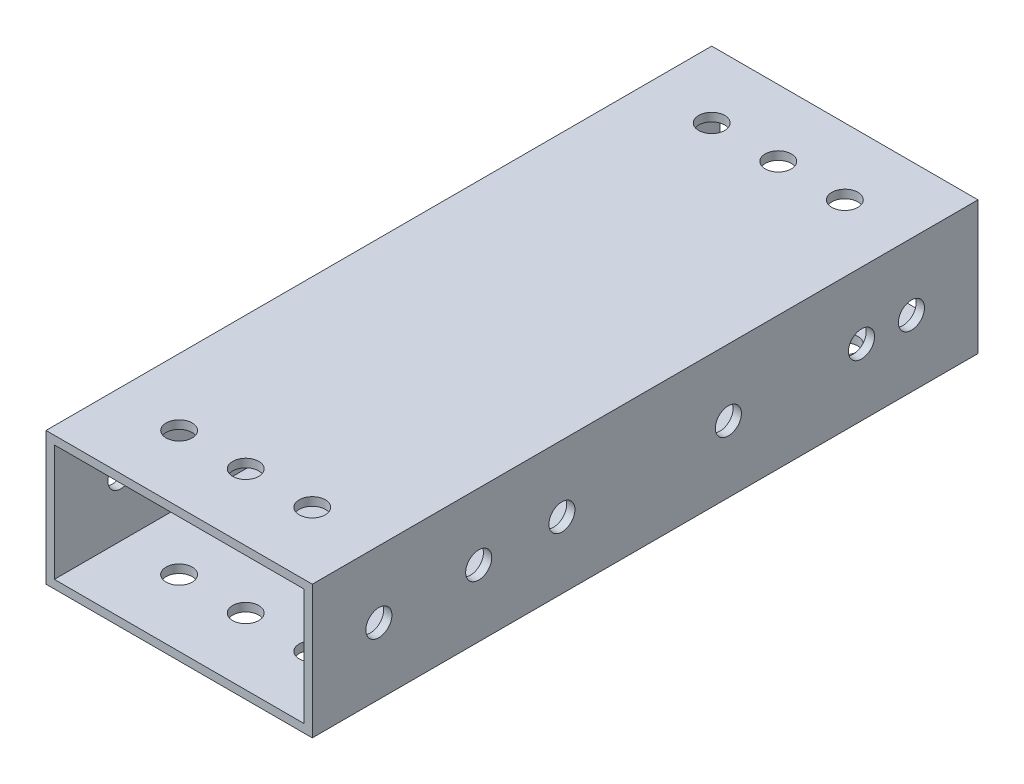
from build123d import *

# Parameters (mm, degrees)
SKETCH1_W           = 50.8
SKETCH1_H           = 25.4
SKETCH1_W_2         = 47.625
SKETCH1_H_2         = 22.225
BOSS_EXTRUDE1_DEPTH = 63.5
SKETCH2_R           = 2.4892
CUT_EXTRUDE1_DEPTH  = 26.4
SKETCH3_R           = 2.4892
CUT_EXTRUDE2_DEPTH  = 51.8


with BuildPart() as part:
    # Sketch1 → Boss-Extrude1 (new body, symmetric)
    with BuildSketch(Plane.XY):
        Rectangle(SKETCH1_W, SKETCH1_H)
        Rectangle(SKETCH1_W_2, SKETCH1_H_2, mode=Mode.SUBTRACT)
    extrude(amount=BOSS_EXTRUDE1_DEPTH, both=True)

    # Sketch2 → Cut-Extrude1 (cut, through all)
    with BuildSketch(Plane(origin=(0, 12.7, 0), x_dir=(1, 0, 0), z_dir=(0, 1, 0))):
        with Locations((-12.7, 50.8)):
            Circle(SKETCH2_R)
        with Locations((0, 50.8)):
            Circle(SKETCH2_R)
        with Locations((12.7, 50.8)):
            Circle(SKETCH2_R)
        with Locations((12.7, -50.8)):
            Circle(SKETCH2_R)
        with Locations((0, -50.8)):
            Circle(SKETCH2_R)
        with Locations((-12.7, -50.8)):
            Circle(SKETCH2_R)
    extrude(amount=-CUT_EXTRUDE1_DEPTH, mode=Mode.SUBTRACT)

    # Sketch3 → Cut-Extrude2 (cut, through all)
    with BuildSketch(Plane(origin=(25.4, 0, 0), x_dir=(0, 0, -1), z_dir=(1, 0, 0))):
        with Locations((50.8, 0)):
            Circle(SKETCH3_R)
        with Locations((41.275, 0)):
            Circle(SKETCH3_R)
        with Locations((15.875, 0)):
            Circle(SKETCH3_R)
        with Locations((-50.8, 0)):
            Circle(SKETCH3_R)
        with Locations((-31.75, 0)):
            Circle(SKETCH3_R)
        with Locations((-15.875, 0)):
            Circle(SKETCH3_R)
    extrude(amount=-CUT_EXTRUDE2_DEPTH, mode=Mode.SUBTRACT)


solid = part.part
